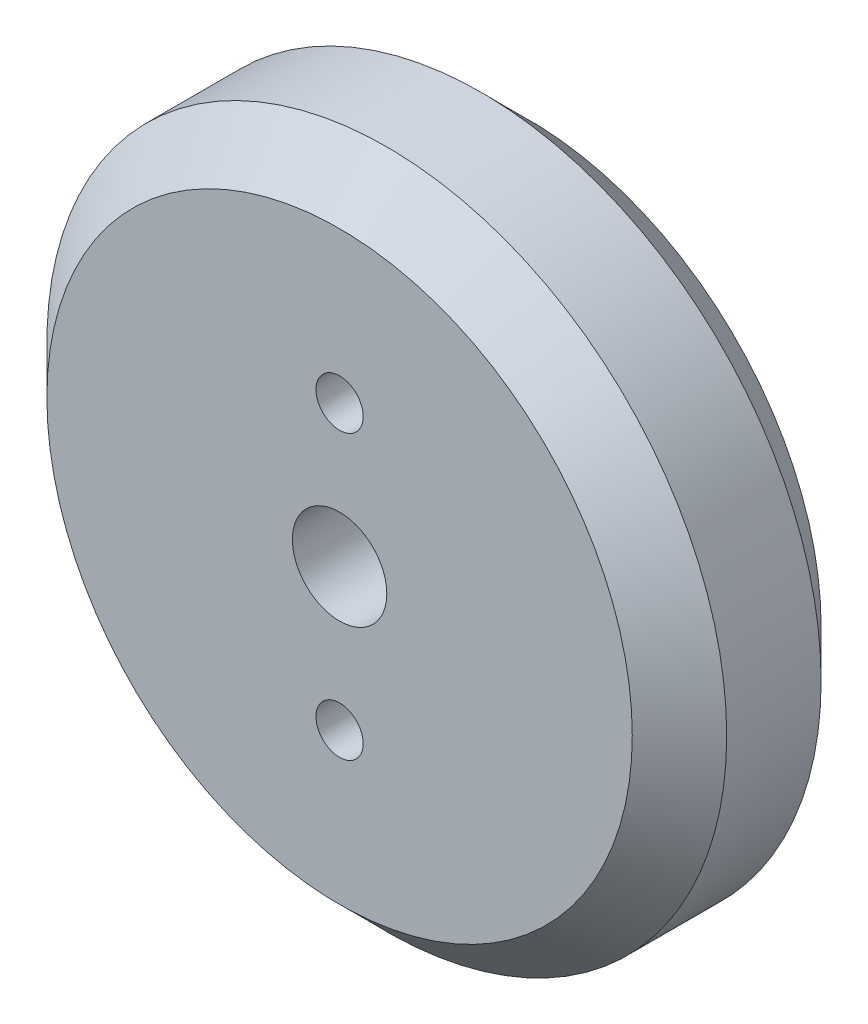
from build123d import *

# Parameters (mm, degrees)
SKETCH_1_R      = 36
SKETCH_1_R_2    = 5
SKETCH_1_R_3    = 2.5
EXTRUDE_1_DEPTH = 20
CHAMFER_1_SIZE  = 5


with BuildPart() as part:
    # 草圖1 → 填料-伸長1 (new body)
    with BuildSketch(Plane.XY):
        Circle(SKETCH_1_R)
        Circle(SKETCH_1_R_2, mode=Mode.SUBTRACT)
        with Locations((0, 15)):
            Circle(SKETCH_1_R_3, mode=Mode.SUBTRACT)
        with Locations((0, -15)):
            Circle(SKETCH_1_R_3, mode=Mode.SUBTRACT)
    extrude(amount=EXTRUDE_1_DEPTH)

    # 導角1
    chamfer_1_edges = [part.edges().sort_by_distance(p)[0] for p in [
        (-36, 0, 0),
        (-36, 0, 20),
    ]]
    chamfer(chamfer_1_edges, length=CHAMFER_1_SIZE)


solid = part.part
